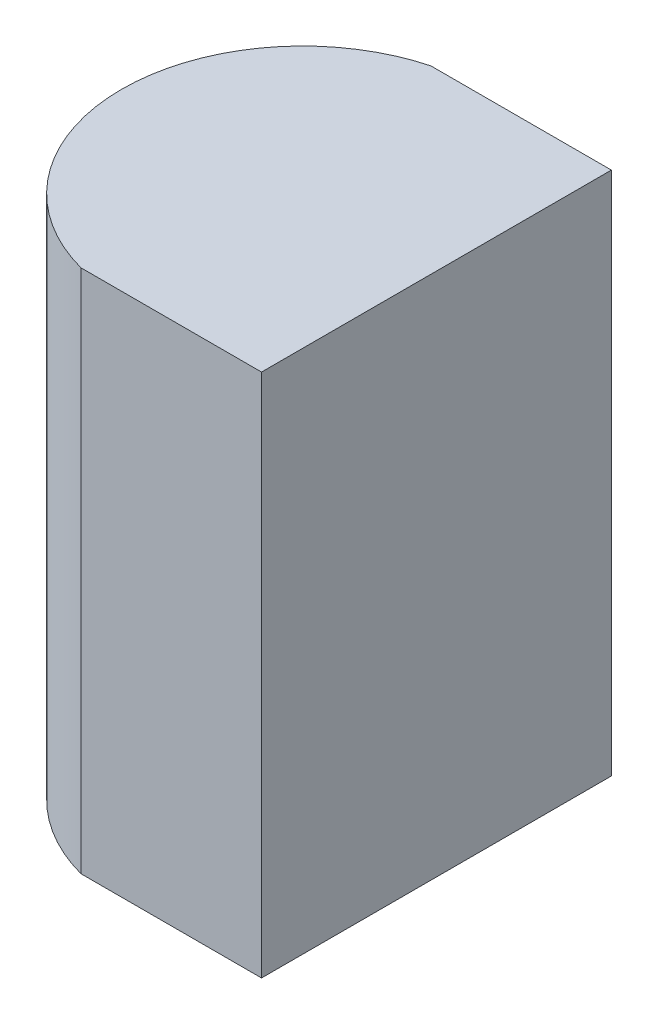
from build123d import *

# Parameters (mm, degrees)
EXTRUDE_1_DEPTH = 6


with BuildPart() as part:
    # 草图1 → 凸台-拉伸1 (new body)
    with BuildSketch(Plane(origin=(0, 0, 0), x_dir=(1, 0, 0), z_dir=(0, 1, 0))):
        with BuildLine():
            Line((0, 0), (0, -4))
            Line((0, -4), (-2.063760246, -4))
            ThreePointArc((-2.063760246, -4), (-3.6, -2), (-2.063760246, 0))
            Line((-2.063760246, 0), (0, 0))
        make_face()
    extrude(amount=EXTRUDE_1_DEPTH)


solid = part.part
